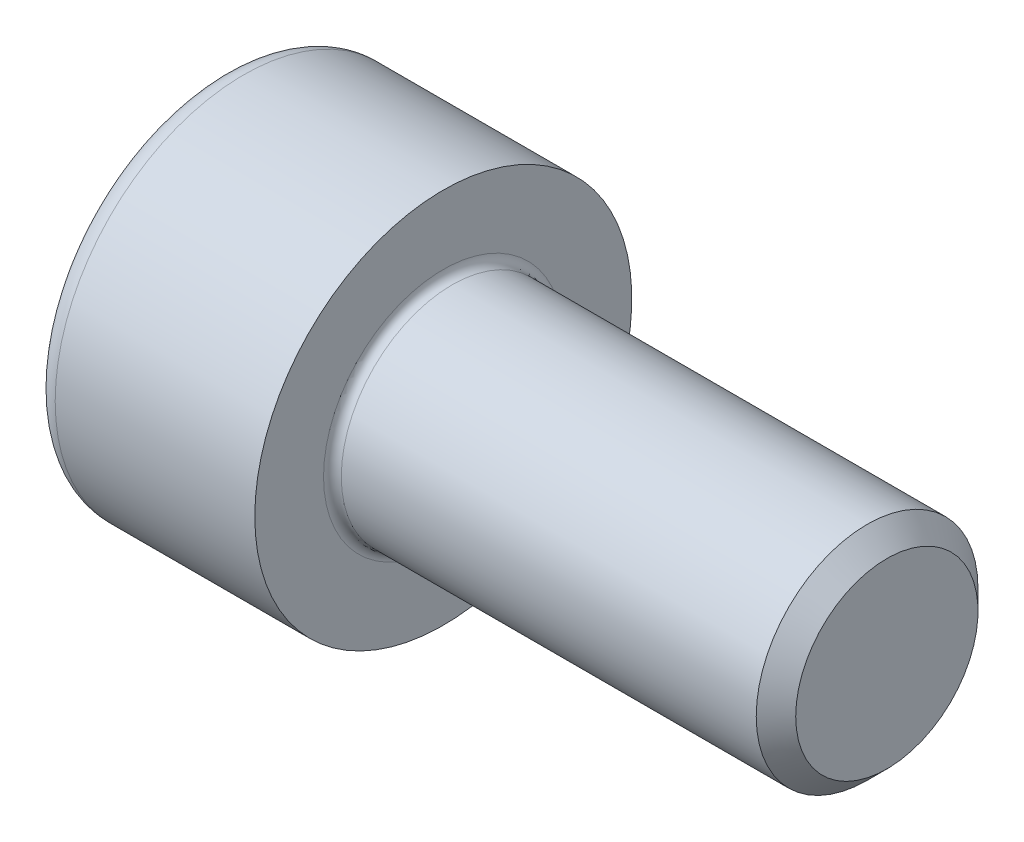
from build123d import *

# Parameters (mm, degrees)
FILLET1_R   = 0.2
FILLET2_R   = 0.5
HEX_2_DEPTH = 2.5


with BuildPart() as part:
    # BodySke → Base-Revolve (revolve)
    with BuildSketch(Plane.XY):
        Polygon((0, 0), (0, 4.25), (5, 4.25), (5, 2.5), (14.555, 2.5), (15, 2.055), (15, 0), align=None)
    revolve(axis=Axis((-31.75, 0, 0), (1, 0, 0)))

    # Fillet1
    fillet1_edges = [part.edges().sort_by_distance(p)[0] for p in [
        (5, -2.5, 0),
    ]]
    fillet(fillet1_edges, radius=FILLET1_R)

    # Fillet2
    fillet2_edges = [part.edges().sort_by_distance(p)[0] for p in [
        (0, -4.25, 0),
    ]]
    fillet(fillet2_edges, radius=FILLET2_R)

    # Sketch2 → Hex-PreBroach (revolve, cut)
    with BuildSketch(Plane.XY):
        Polygon((0, 2.01), (2.5, 2.01), (3.660474041, 0), (0, 0), align=None)
    revolve(axis=Axis((0, 0, 0), (1, 0, 0)), mode=Mode.SUBTRACT)

    # Sketch3 → Hex 2 (cut)
    with BuildSketch(Plane(origin=(0, 0, 0), x_dir=(0, 0.5, 0.866025404), z_dir=(-1, 0, 0))):
        Polygon((1.160474041, 2.01), (-1.160474041, 2.01), (-2.320948082, 0), (-1.160474041, -2.01), (1.160474041, -2.01), (2.320948082, 0), align=None)
    extrude(amount=-HEX_2_DEPTH, mode=Mode.SUBTRACT)


solid = part.part
